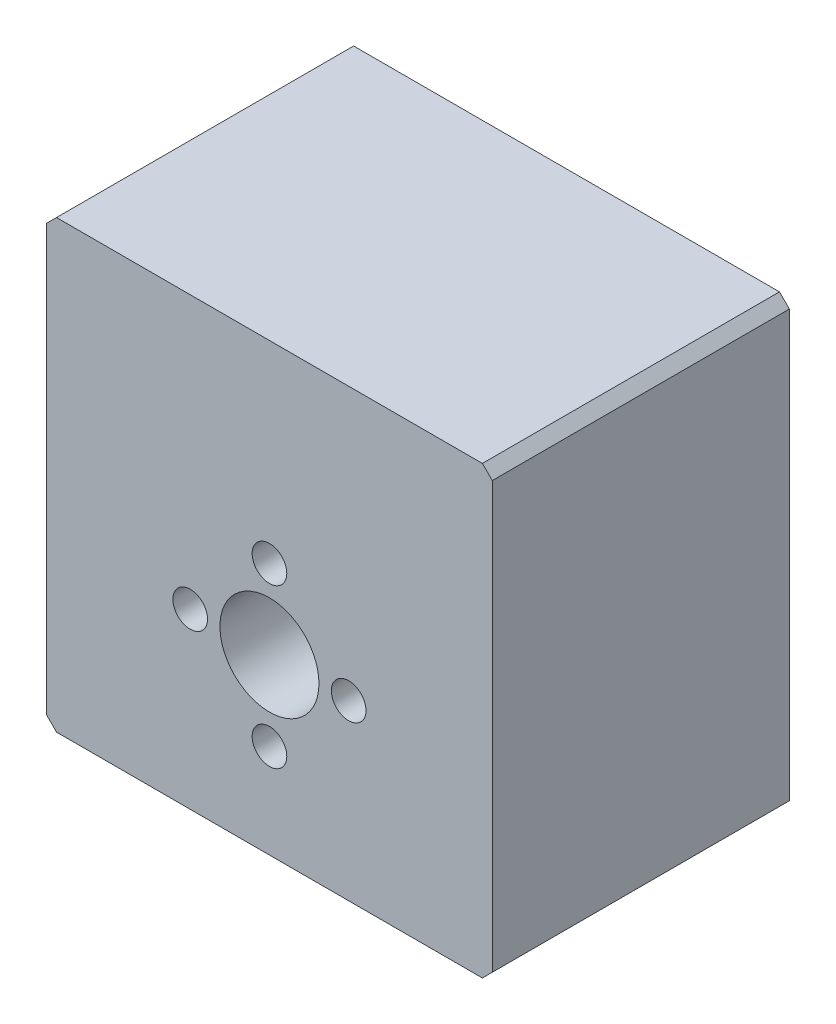
from build123d import *

# Parameters (mm, degrees)
SKETCH1_W           = 45
SKETCH1_H           = 45
SKETCH1_R           = 5
BOSS_EXTRUDE1_DEPTH = 15
SKETCH2_R           = 1.75
CUT_EXTRUDE1_DEPTH  = 10
CHAMFER1_SIZE       = 1
SKETCH3_R           = 2
CUT_EXTRUDE2_DEPTH  = 10


with BuildPart() as part:
    # Sketch1 → Boss-Extrude1 (new body, symmetric)
    with BuildSketch(Plane.XY):
        with Locations((0, 5)):
            Rectangle(SKETCH1_W, SKETCH1_H)
        Circle(SKETCH1_R, mode=Mode.SUBTRACT)
    extrude(amount=BOSS_EXTRUDE1_DEPTH, both=True)

    # Sketch2 → Cut-Extrude1 (cut)
    with BuildSketch(Plane.XY.offset(15)):
        with Locations((0, 8)):
            Circle(SKETCH2_R)
        with Locations((0, -8)):
            Circle(SKETCH2_R)
        with Locations((8, 0)):
            Circle(SKETCH2_R)
        with Locations((-8, 0)):
            Circle(SKETCH2_R)
    extrude(amount=-CUT_EXTRUDE1_DEPTH, mode=Mode.SUBTRACT)

    # Chamfer1
    chamfer1_edges = [part.edges().sort_by_distance(p)[0] for p in [
        (-22.5, 27.5, 0),
        (22.5, 27.5, 0),
        (22.5, -17.5, 0),
        (-22.5, -17.5, 0),
    ]]
    chamfer(chamfer1_edges, length=CHAMFER1_SIZE)

    # Sketch3 → Cut-Extrude2 (cut)
    with BuildSketch(Plane.XZ.offset(17.5)):
        with Locations((15, 8)):
            Circle(SKETCH3_R)
        with Locations((15, -8)):
            Circle(SKETCH3_R)
    cut_extrude2 = extrude(amount=-CUT_EXTRUDE2_DEPTH, mode=Mode.SUBTRACT)

    # Mirror1: Cut-Extrude2 across plane
    add(cut_extrude2.mirror(Plane(origin=(0, 0, 0), x_dir=(0, 0, 1), z_dir=(1, 0, 0))), mode=Mode.SUBTRACT)


solid = part.part
